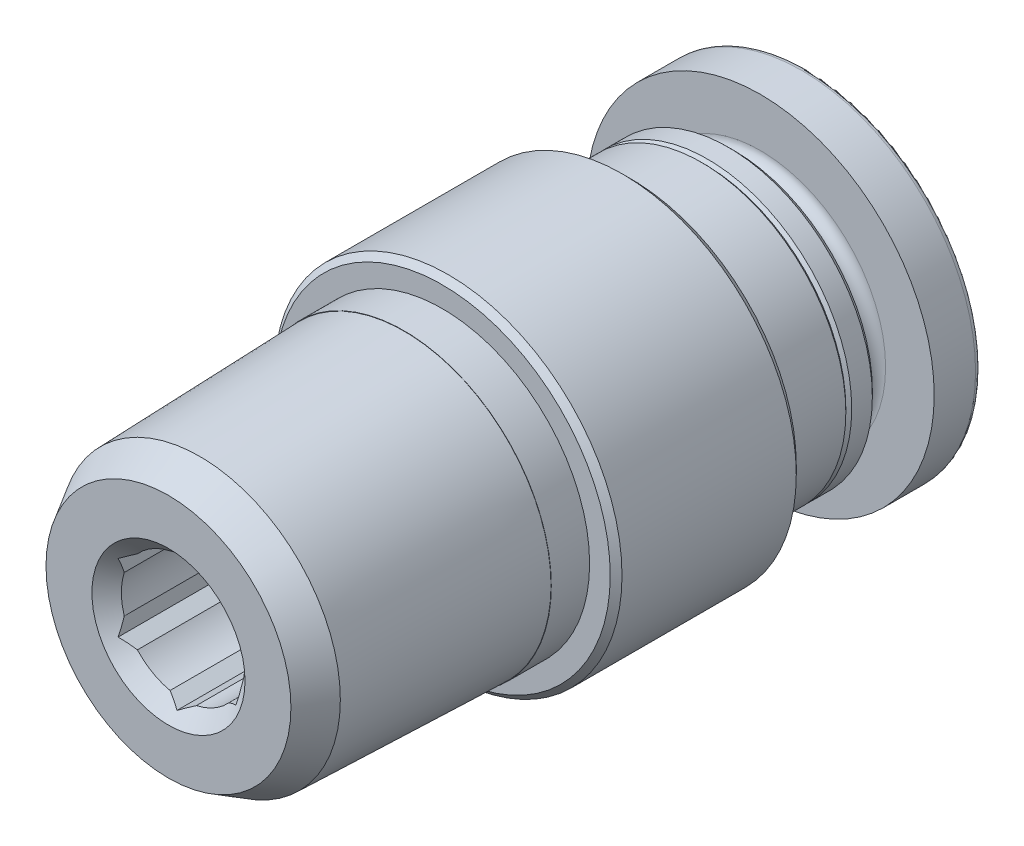
from build123d import *

# Parameters (mm, degrees)
CUT_EXTRUDE1_DEPTH = 5.1


with BuildPart() as part:
    # Sketch1 → Revolve1 (revolve)
    with BuildSketch(Plane(origin=(0, 0, 0), x_dir=(0, 0, -1), z_dir=(1, 0, 0))):
        with BuildLine():
            Line((0, 0), (0, 5.9))
            Line((0, 5.9), (7.417157288, 5.9))
            Line((7.417157288, 5.9), (7.7, 5.617157288))
            Line((7.7, 5.617157288), (7.7, 4.9))
            Line((7.7, 4.9), (10.1, 4.9))
            Line((10.1, 4.9), (10.2, 4.8))
            Line((10.2, 4.8), (10.3, 4.9))
            Line((10.3, 4.9), (11, 4.9))
            Line((11, 4.9), (11.2, 4.7))
            Line((11.2, 4.7), (11.2, 3.875))
            Line((11.2, 3.875), (11.725, 3.875))
            ThreePointArc((11.725, 3.875), (11.990165043, 3.984834957), (12.1, 4.25))
            Line((12.1, 4.25), (12.1, 5.9))
            Line((12.1, 5.9), (13.504587146, 5.9))
            ThreePointArc((13.504587146, 5.9), (13.633144667, 5.853208889), (13.701548696, 5.734729636))
            Line((13.701548696, 5.734729636), (14.1, 3.475))
            Line((14.1, 3.475), (14.1, 0))
            Line((14.1, 0), (0, 0))
        make_face()
    revolve(axis=Axis((0, 0, -14.1), (0, 0, 1)))

    # Sketch2 → Revolve2 (revolve)
    with BuildSketch(Plane(origin=(0, 0, 0), x_dir=(0, 0, -1), z_dir=(1, 0, 0))):
        Polygon((-8, 0), (-8, 4.158121832), (-6.93615215, 4.772334675), (0, 4.988878168), (0, 0), align=None)
    revolve(axis=Axis((0, 0, 0), (0, 0, 1)))

    # Sketch3 → Cut-Revolve1 (revolve, cut)
    with BuildSketch(Plane(origin=(0, 0, 0), x_dir=(0, 0, -1), z_dir=(1, 0, 0))):
        Polygon((0, 5.9), (0, 5), (1.3, 5), (1.3, 5.7), (1.5, 5.9), align=None)
    revolve(axis=Axis((0, 0, -50), (0, 0, 1)), mode=Mode.SUBTRACT)

    # Sketch4 → Cut-Revolve2 (revolve, cut)
    with BuildSketch(Plane(origin=(0, 0, 0), x_dir=(0, 0, -1), z_dir=(1, 0, 0))):
        with BuildLine():
            Line((-8, 0), (-8, 2.6))
            Line((-8, 2.6), (-7.5, 2.1))
            Line((-7.5, 2.1), (-2.9, 2.1))
            Line((-2.9, 2.1), (-2.9, 3.175))
            Line((-2.9, 3.175), (13.8, 3.175))
            ThreePointArc((13.8, 3.175), (14.012132034, 3.262867966), (14.1, 3.475))
            Line((14.1, 3.475), (14.1, 0))
            Line((14.1, 0), (-8, 0))
        make_face()
    revolve(axis=Axis((0, 0, -14.1), (0, 0, 1)), mode=Mode.SUBTRACT)

    # Sketch5 → Cut-Extrude1 (cut)
    with BuildSketch(Plane.XY.offset(2.9)):
        Polygon((-2, -1.154700538), (0, -2.309401077), (2, -1.154700538), (2, 1.154700538), (0, 2.309401077), (-2, 1.154700538), align=None)
    extrude(amount=CUT_EXTRUDE1_DEPTH, mode=Mode.SUBTRACT)


solid = part.part
